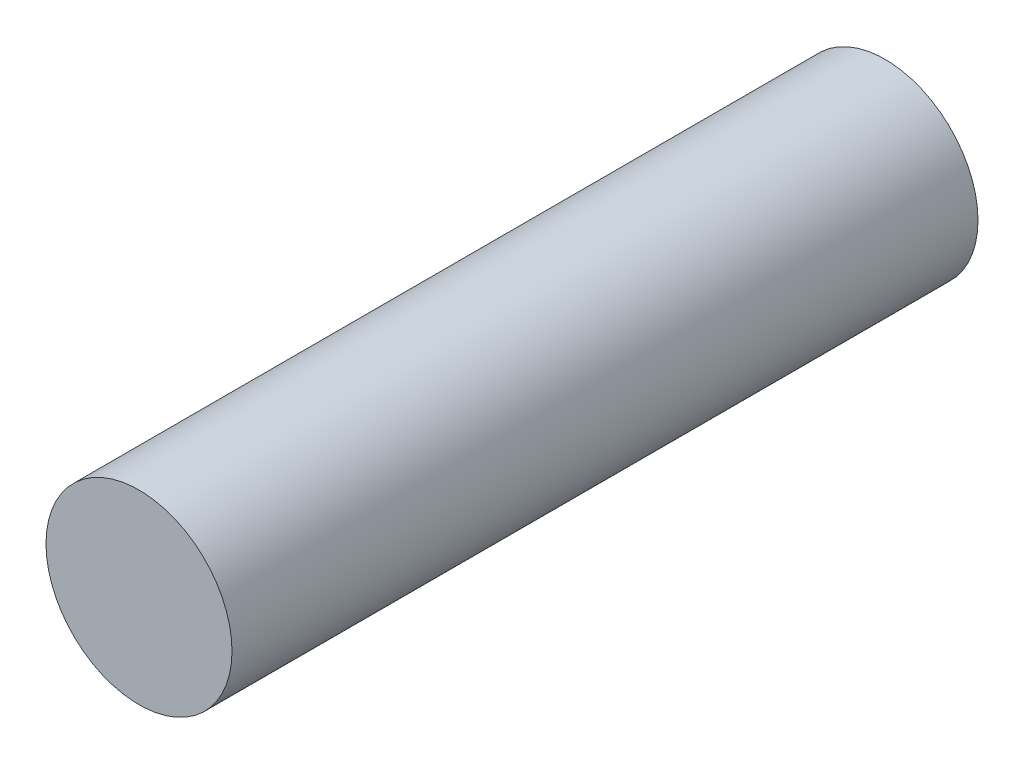
from build123d import *

# Parameters (mm, degrees)
SKETCH1_R           = 0.935
BOSS_EXTRUDE1_DEPTH = 7.5


with BuildPart() as part:
    # Sketch1 → Boss-Extrude1 (new body)
    with BuildSketch(Plane.XY):
        Circle(SKETCH1_R)
    extrude(amount=BOSS_EXTRUDE1_DEPTH)


solid = part.part
